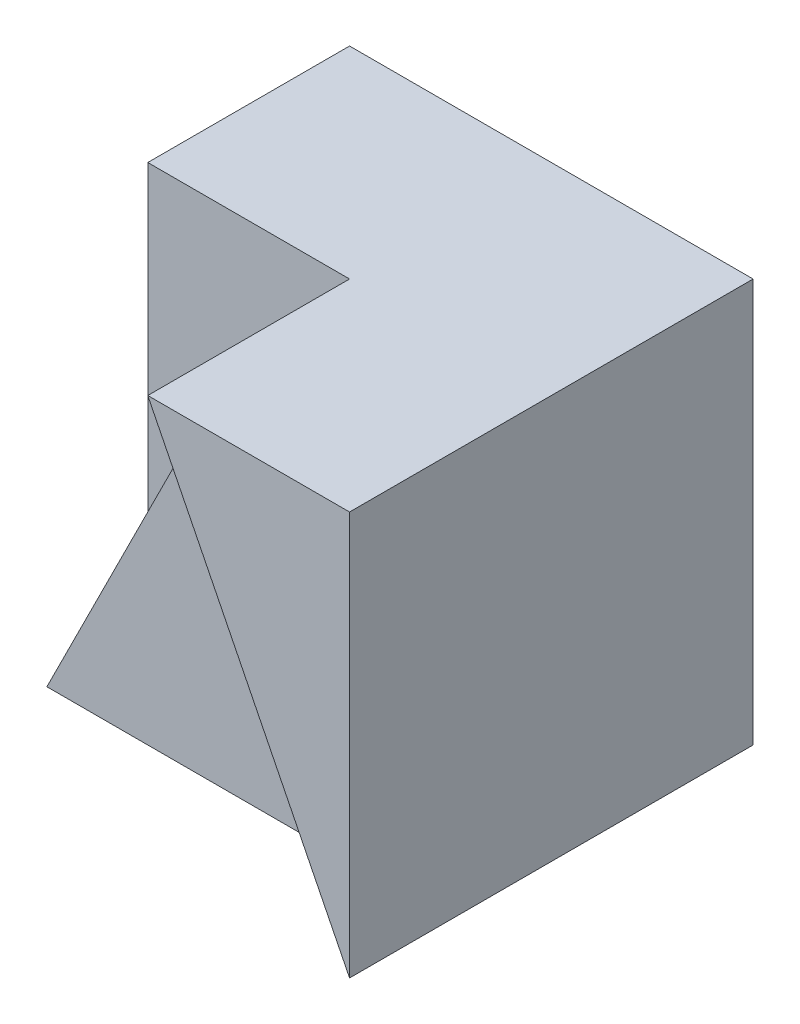
from build123d import *

# Parameters (mm, degrees)
SKETCH1_W           = 4
SKETCH1_H           = 4
BOSS_EXTRUDE1_DEPTH = 4
CUT_EXTRUDE3_DEPTH  = 2
CUT_EXTRUDE4_DEPTH  = 1


with BuildPart() as part:
    # Sketch1 → Boss-Extrude1 (new body)
    with BuildSketch(Plane(origin=(0, 0, 0), x_dir=(1, 0, 0), z_dir=(0, 1, 0))):
        Rectangle(SKETCH1_W, SKETCH1_H)
    extrude(amount=BOSS_EXTRUDE1_DEPTH)

    # Sketch6 → Cut-Extrude3 (cut)
    with BuildSketch(Plane.XY.offset(2)):
        Polygon((0, 4), (-2, 4), (-2, 0), align=None)
    extrude(amount=-CUT_EXTRUDE3_DEPTH, mode=Mode.SUBTRACT)

    # Sketch7 → Cut-Extrude4 (cut)
    with BuildSketch(Plane.XY.offset(2)):
        Polygon((0, 4), (-2, 0), (2, 0), align=None)
    extrude(amount=-CUT_EXTRUDE4_DEPTH, mode=Mode.SUBTRACT)


solid = part.part
